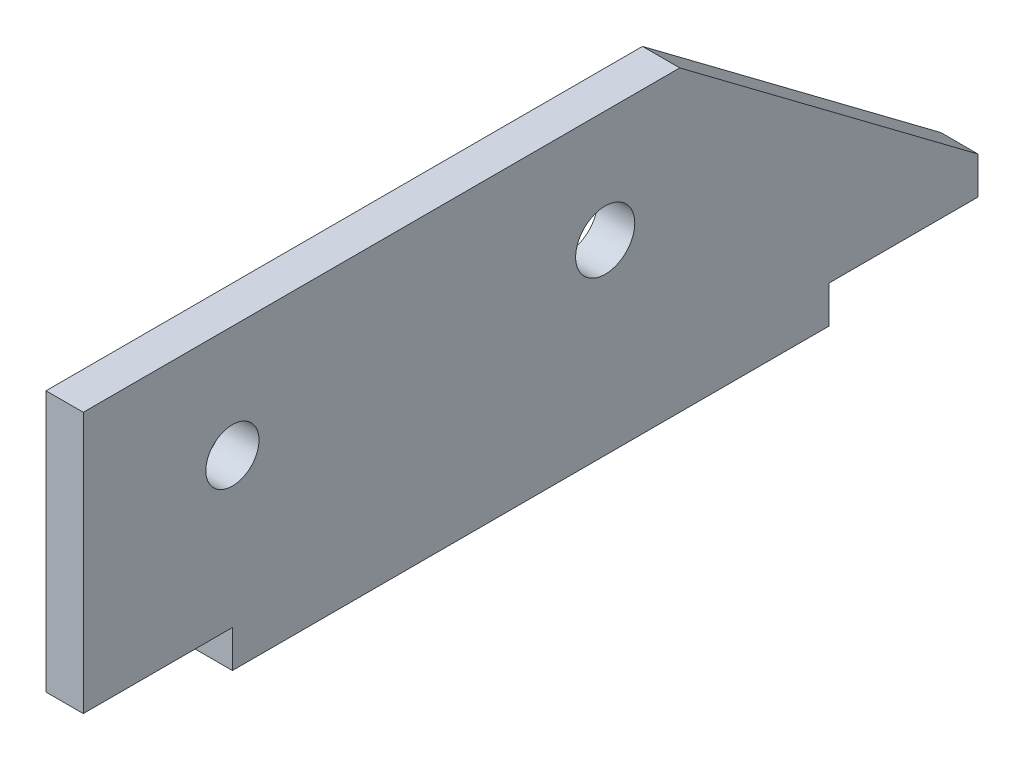
from build123d import *

# Parameters (mm, degrees)
BOSS_EXTRUDE1_DEPTH = 3.175
SKETCH2_R           = 2.264660361
SKETCH2_R_2         = 2.519309543
SKETCH2_W           = 12.7
SKETCH2_H           = 3.175
CUT_EXTRUDE1_DEPTH  = 3.175


with BuildPart() as part:
    # Sketch1 → Boss-Extrude1 (new body)
    with BuildSketch(Plane(origin=(0, 0, 0), x_dir=(0, 0, -1), z_dir=(1, 0, 0))):
        Polygon((50.8, 25.4), (76.2, 6.35), (76.2, 0), (0, 0), (0, 25.4), align=None)
    extrude(amount=BOSS_EXTRUDE1_DEPTH)

    # Sketch2 → Cut-Extrude1 (cut)
    with BuildSketch(Plane(origin=(3.175, 0, 0), x_dir=(0, 0, -1), z_dir=(1, 0, 0))):
        with Locations((12.7, 15.875)):
            Circle(SKETCH2_R)
        with Locations((44.45, 15.875)):
            Circle(SKETCH2_R_2)
        with Locations((6.35, 1.5875)):
            Rectangle(SKETCH2_W, SKETCH2_H)
        with Locations((69.85, 1.5875)):
            Rectangle(SKETCH2_W, SKETCH2_H)
    extrude(amount=-CUT_EXTRUDE1_DEPTH, mode=Mode.SUBTRACT)


solid = part.part
